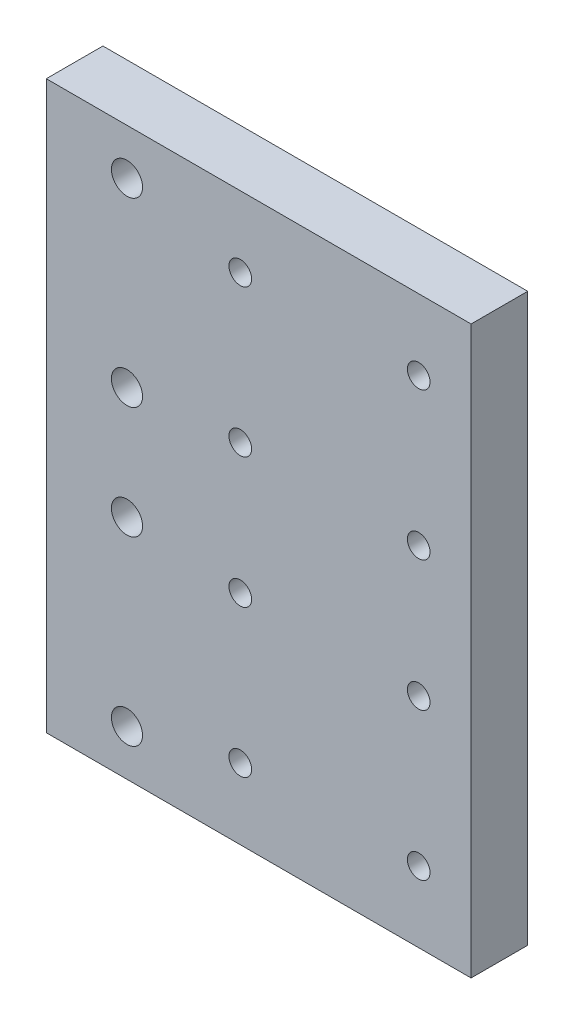
from build123d import *

# Parameters (mm, degrees)
SKETCH1_W           = 75
SKETCH1_H           = 100
SKETCH1_R           = 2
SKETCH1_R_2         = 2.75
BOSS_EXTRUDE1_DEPTH = 10


with BuildPart() as part:
    # Sketch1 → Boss-Extrude1 (new body)
    with BuildSketch(Plane.XY):
        with Locations((-37.5, 0)):
            Rectangle(SKETCH1_W, SKETCH1_H)
        with Locations((-40.75, 37.5)):
            Circle(SKETCH1_R, mode=Mode.SUBTRACT)
        with Locations((-9.25, 37.5)):
            Circle(SKETCH1_R, mode=Mode.SUBTRACT)
        with Locations((-40.75, 11.5)):
            Circle(SKETCH1_R, mode=Mode.SUBTRACT)
        with Locations((-9.25, 11.5)):
            Circle(SKETCH1_R, mode=Mode.SUBTRACT)
        with Locations((-40.75, -11.5)):
            Circle(SKETCH1_R, mode=Mode.SUBTRACT)
        with Locations((-9.25, -11.5)):
            Circle(SKETCH1_R, mode=Mode.SUBTRACT)
        with Locations((-9.25, -37.5)):
            Circle(SKETCH1_R, mode=Mode.SUBTRACT)
        with Locations((-40.75, -37.5)):
            Circle(SKETCH1_R, mode=Mode.SUBTRACT)
        with Locations((-60.75, 41.904631992)):
            Circle(SKETCH1_R_2, mode=Mode.SUBTRACT)
        with Locations((-60.75, 9.904631992)):
            Circle(SKETCH1_R_2, mode=Mode.SUBTRACT)
        with Locations((-60.75, -9.904631992)):
            Circle(SKETCH1_R_2, mode=Mode.SUBTRACT)
        with Locations((-60.75, -41.904631992)):
            Circle(SKETCH1_R_2, mode=Mode.SUBTRACT)
    extrude(amount=BOSS_EXTRUDE1_DEPTH)


solid = part.part
